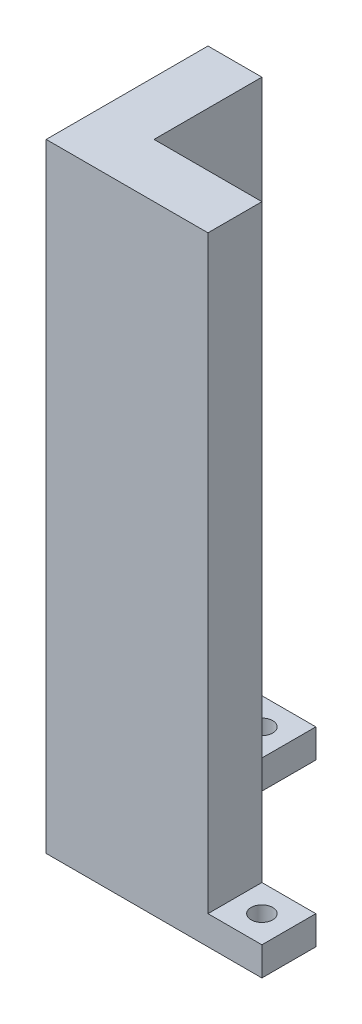
from build123d import *

# Parameters (mm, degrees)
SKETCH1_R           = 1.5
BOSS_EXTRUDE1_DEPTH = 4
BOSS_EXTRUDE2_DEPTH = 82


with BuildPart() as part:
    # Sketch1 → Boss-Extrude1 (new body)
    with BuildSketch(Plane(origin=(0, 0, 0), x_dir=(1, 0, 0), z_dir=(0, 1, 0))):
        Polygon((0, 0), (15, 0), (22.5, 0), (22.5, -7.5), (15, -7.5), (-7.5, -7.5), (-7.5, 22.5), (0, 22.5), (0, 15), align=None)
        with Locations((-3.75, 18.75)):
            Circle(SKETCH1_R, mode=Mode.SUBTRACT)
        with Locations((18.75, -3.75)):
            Circle(SKETCH1_R, mode=Mode.SUBTRACT)
    extrude(amount=BOSS_EXTRUDE1_DEPTH)

    # Sketch3 → Boss-Extrude2 (add)
    with BuildSketch(Plane(origin=(0, 4, 0), x_dir=(1, 0, 0), z_dir=(0, 1, 0))):
        Polygon((0, 0), (0, 15), (-7.5, 15), (-7.5, -7.5), (15, -7.5), (15, 0), align=None)
    extrude(amount=BOSS_EXTRUDE2_DEPTH)


solid = part.part
